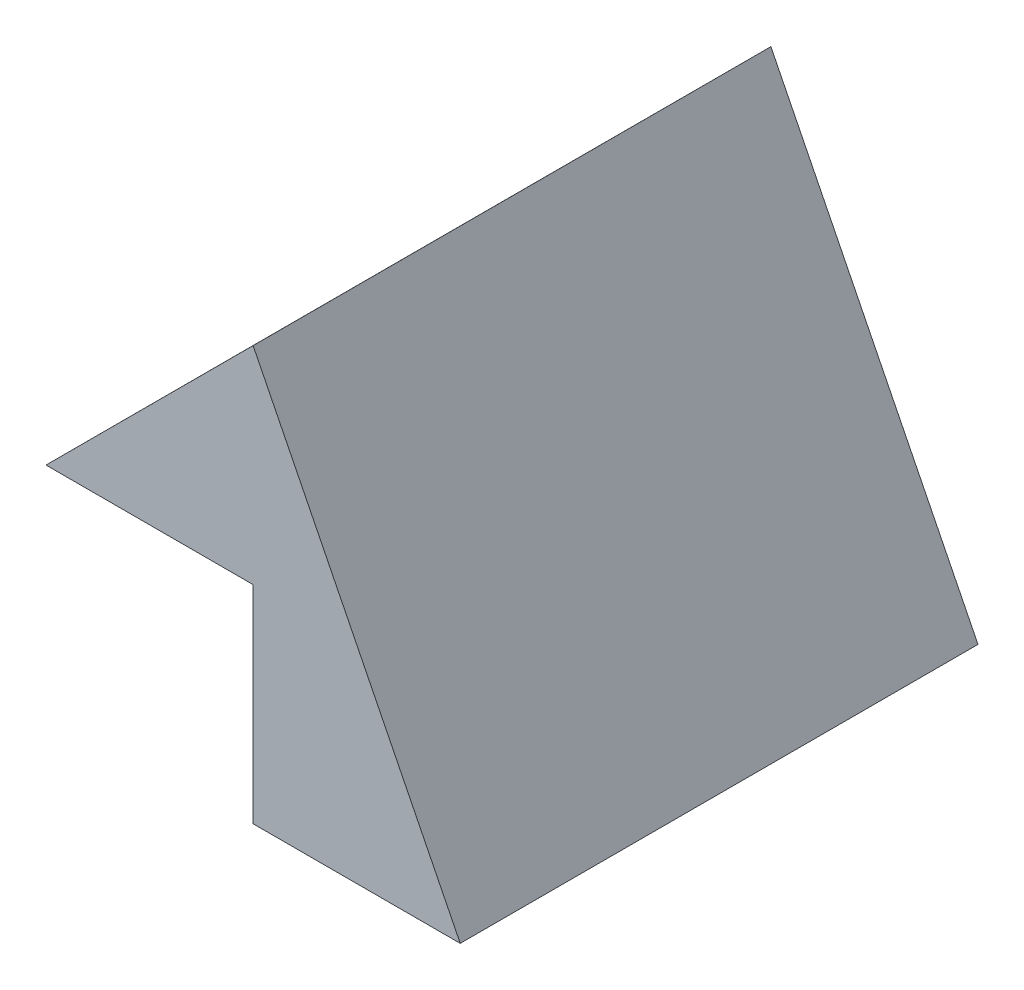
from build123d import *

# Parameters (mm, degrees)
BOSS_EXTRUDE1_DEPTH = 25


with BuildPart() as part:
    # Sketch1 → Boss-Extrude1 (new body)
    with BuildSketch(Plane.XY):
        Polygon((-20, 10), (-10, 19.996086474), (0, 0), (-10, 0), (-10, 10), align=None)
    extrude(amount=BOSS_EXTRUDE1_DEPTH)


solid = part.part
